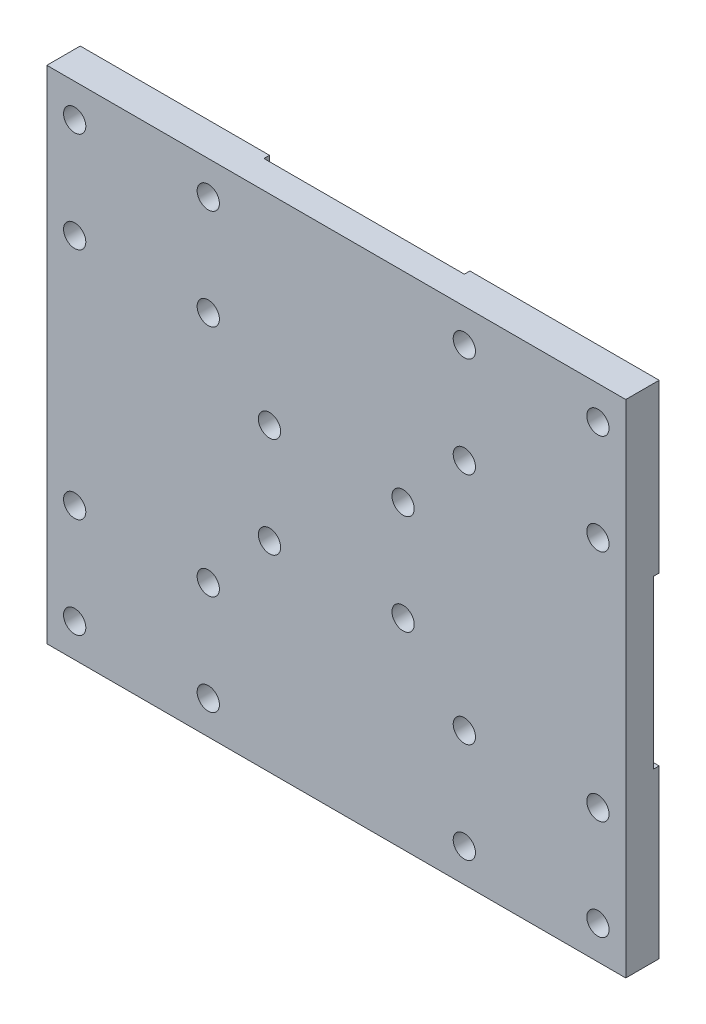
from build123d import *

# Parameters (mm, degrees)
CROQUIS1_W              = 104
CROQUIS1_H              = 90
SALIENTE_EXTRUIR1_DEPTH = 5
CROQUIS3_W              = 34
CROQUIS3_H              = 30
SALIENTE_EXTRUIR2_DEPTH = 1
SKETCH1_R               = 2
CUT_EXTRUDE1_DEPTH      = 5


with BuildPart() as part:
    # Croquis1 → Saliente-Extruir1 (new body)
    with BuildSketch(Plane.XY):
        Rectangle(CROQUIS1_W, CROQUIS1_H)
    extrude(amount=SALIENTE_EXTRUIR1_DEPTH)

    # Croquis3 → Saliente-Extruir2 (add)
    with BuildSketch(Plane(origin=(0, 0, 0), x_dir=(-1, 0, 0), z_dir=(0, 0, -1))):
        with Locations((-35, 30)):
            Rectangle(CROQUIS3_W, CROQUIS3_H)
        with Locations((-35, -30)):
            Rectangle(CROQUIS3_W, CROQUIS3_H)
        with Locations((35, 30)):
            Rectangle(CROQUIS3_W, CROQUIS3_H)
        with Locations((35, -30)):
            Rectangle(CROQUIS3_W, CROQUIS3_H)
    extrude(amount=SALIENTE_EXTRUIR2_DEPTH)

    # Sketch1 → Cut-Extrude1 (cut)
    with BuildSketch(Plane(origin=(0, 0, 0), x_dir=(-1, 0, 0), z_dir=(0, 0, -1))):
        with Locations((-47, 39)):
            Circle(SKETCH1_R)
        with Locations((-23, 39)):
            Circle(SKETCH1_R)
        with Locations((-47, 21)):
            Circle(SKETCH1_R)
        with Locations((-23, 21)):
            Circle(SKETCH1_R)
        with Locations((23, 39)):
            Circle(SKETCH1_R)
        with Locations((23, 21)):
            Circle(SKETCH1_R)
        with Locations((47, 21)):
            Circle(SKETCH1_R)
        with Locations((47, 39)):
            Circle(SKETCH1_R)
        with Locations((23, -21)):
            Circle(SKETCH1_R)
        with Locations((23, -39)):
            Circle(SKETCH1_R)
        with Locations((47, -39)):
            Circle(SKETCH1_R)
        with Locations((47, -21)):
            Circle(SKETCH1_R)
        with Locations((-23, -21)):
            Circle(SKETCH1_R)
        with Locations((-23, -39)):
            Circle(SKETCH1_R)
        with Locations((-47, -39)):
            Circle(SKETCH1_R)
        with Locations((-47, -21)):
            Circle(SKETCH1_R)
        with Locations((-12, 9)):
            Circle(SKETCH1_R)
        with Locations((-12, -9)):
            Circle(SKETCH1_R)
        with Locations((12, -9)):
            Circle(SKETCH1_R)
        with Locations((12, 9)):
            Circle(SKETCH1_R)
    extrude(amount=-CUT_EXTRUDE1_DEPTH, mode=Mode.SUBTRACT)


solid = part.part
